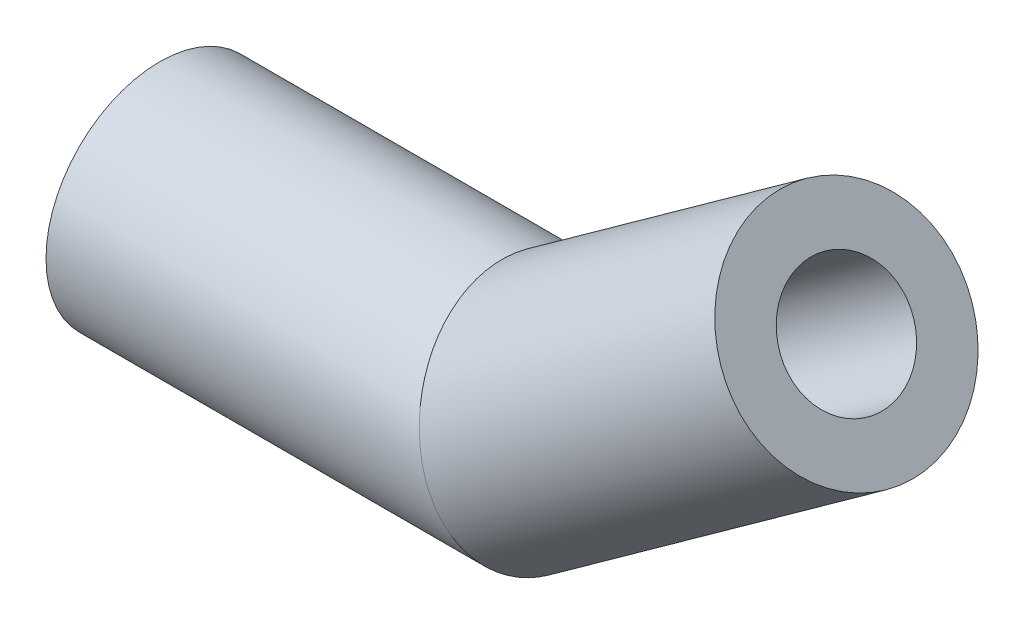
from build123d import *

# Parameters (mm, degrees)
SWEEP1_PROFILE_R   = 3
SKETCH3_R          = 1.6
CUT_EXTRUDE1_DEPTH = 7


with BuildPart() as part:
    # Sweep1: sweep along a path in Sketch2
    with BuildLine(Plane.XY) as sweep1_path:
        Line((0, 0), (10, 0))
        Line((10, 0), (18.119816674, 5.836829378))
    # Sweep1 profile (on start of the path) → Sweep1 (sweep)
    with BuildSketch(Plane(origin=(0, 0, 0), x_dir=(0, 0, 1), z_dir=(1, 0, 0))):
        Circle(SWEEP1_PROFILE_R)
    sweep(path=sweep1_path.line, transition=Transition.RIGHT)

    # Sketch3 → Cut-Extrude1 (cut)
    with BuildSketch(Plane(origin=(0, 0, 0), x_dir=(0, 0, -1), z_dir=(1, 0, 0))):
        Circle(SKETCH3_R)
    cut_extrude1 = extrude(amount=CUT_EXTRUDE1_DEPTH, mode=Mode.SUBTRACT)

    # Mirror1: Cut-Extrude1 across plane
    add(cut_extrude1.mirror(Plane(origin=(9.059908337, 2.918414689, 0), x_dir=(0, 0, 1), z_dir=(0.951835508, 0.306609143, 0))), mode=Mode.SUBTRACT)


solid = part.part
